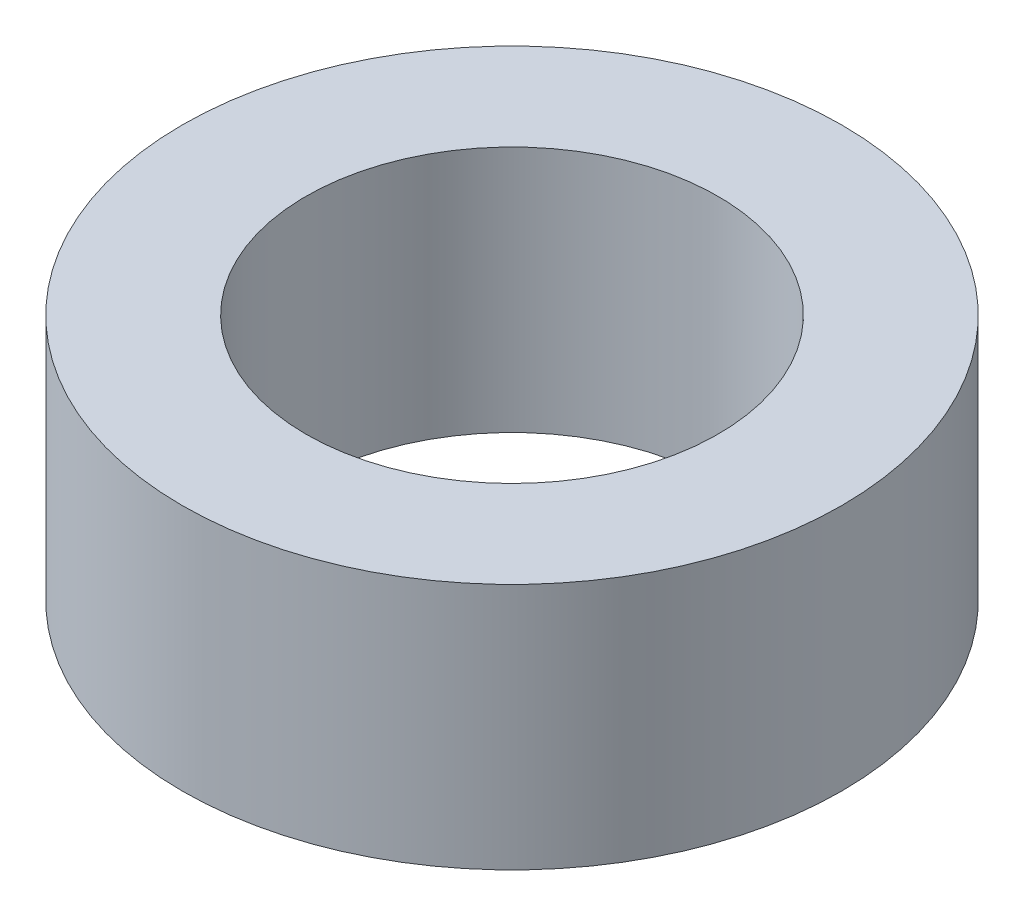
from build123d import *

# Parameters (mm, degrees)
SKETCH1_R           = 4
SKETCH1_R_2         = 2.5
BOSS_EXTRUDE1_DEPTH = 3


with BuildPart() as part:
    # Sketch1 → Boss-Extrude1 (new body)
    with BuildSketch(Plane(origin=(0, 0, 0), x_dir=(1, 0, 0), z_dir=(0, 1, 0))):
        Circle(SKETCH1_R)
        Circle(SKETCH1_R_2, mode=Mode.SUBTRACT)
    extrude(amount=BOSS_EXTRUDE1_DEPTH)


solid = part.part
